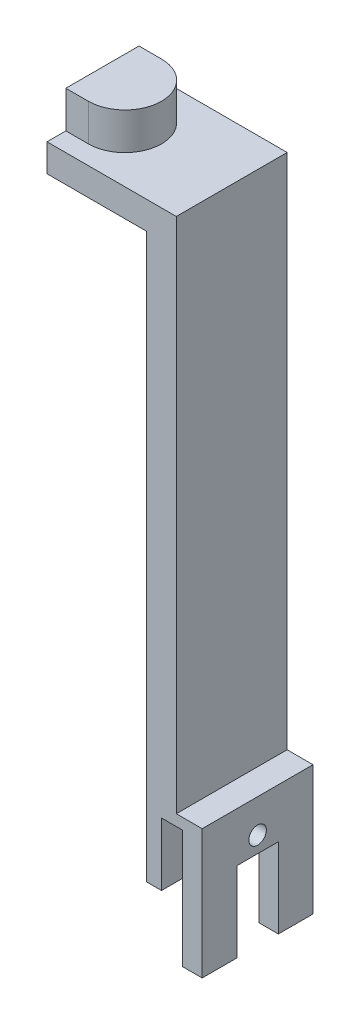
from build123d import *

# Parameters (mm, degrees)
SKETCH_1_W          = 15
SKETCH_1_H          = 30
EXTRUDE_1_DEPTH     = 20
SKETCH_2_W          = 5.7
SKETCH_2_H          = 17
CUT_EXTRUDE_1_DEPTH = 31
SKETCH_3_W          = 8
SKETCH_3_H          = 30
EXTRUDE_2_DEPTH     = 150
SKETCH_4_R          = 2.375
CUT_EXTRUDE_2_DEPTH = 16
SKETCH_5_W          = 30
SKETCH_5_H          = 17.5
EXTRUDE_3_DEPTH     = 27
CUT_EXTRUDE_3_DEPTH = 10
SKETCH_7_W          = 30
SKETCH_7_H          = 15
EXTRUDE_4_DEPTH     = 5.3
CUT_EXTRUDE_4_REACH = 44
SKETCH_8_W          = 11.25
SKETCH_8_H          = 21.625


with BuildPart() as part:
    # 스케치1 → 보스-돌출1 (new body)
    with BuildSketch(Plane(origin=(0, 0, 0), x_dir=(1, 0, 0), z_dir=(0, 1, 0))):
        Rectangle(SKETCH_1_W, SKETCH_1_H)
    extrude(amount=EXTRUDE_1_DEPTH)

    # 스케치2 → 컷-돌출1 (cut, through all)
    with BuildSketch(Plane.XY.offset(15)):
        with Locations((-0.65, 8.5)):
            Rectangle(SKETCH_2_W, SKETCH_2_H)
    extrude(amount=-CUT_EXTRUDE_1_DEPTH, mode=Mode.SUBTRACT)

    # 스케치3 → 보스-돌출2 (add)
    with BuildSketch(Plane(origin=(0, 20, 0), x_dir=(1, 0, 0), z_dir=(0, 1, 0))):
        with Locations((-3.5, 0)):
            Rectangle(SKETCH_3_W, SKETCH_3_H)
    extrude(amount=EXTRUDE_2_DEPTH)

    # 스케치4 → 컷-돌출2 (cut, through all)
    with BuildSketch(Plane(origin=(7.5, 0, 0), x_dir=(0, 0, -1), z_dir=(1, 0, 0))):
        with Locations((0, 11)):
            Circle(SKETCH_4_R)
    extrude(amount=-CUT_EXTRUDE_2_DEPTH, mode=Mode.SUBTRACT)

    # 스케치5 → 보스-돌출3 (add)
    with BuildSketch(Plane.ZY.offset(7.5)):
        with Locations((0, 161.25)):
            Rectangle(SKETCH_5_W, SKETCH_5_H)
    extrude(amount=EXTRUDE_3_DEPTH)

    # 스케치6 → 컷-돌출3 (cut)
    with BuildSketch(Plane(origin=(0, 170, 0), x_dir=(1, 0, 0), z_dir=(0, 1, 0))):
        with BuildLine():
            Line((-34.5, 15), (-34.5, 9.9))
            Line((-34.5, 9.9), (-28.4, 9.9))
            ThreePointArc((-28.4, 9.9), (-18.5, 0), (-28.4, -9.9))
            Line((-28.4, -9.9), (-34.5, -9.9))
            Line((-34.5, -9.9), (-34.5, -15))
            Line((-34.5, -15), (0.5, -15))
            Line((0.5, -15), (0.5, 15))
            Line((0.5, 15), (-34.5, 15))
        make_face()
    extrude(amount=-CUT_EXTRUDE_3_DEPTH, mode=Mode.SUBTRACT)

    # 스케치7 → 보스-돌출4 (add)
    with BuildSketch(Plane(origin=(7.5, 0, 0), x_dir=(0, 0, -1), z_dir=(1, 0, 0))):
        with Locations((0, -7.5)):
            Rectangle(SKETCH_7_W, SKETCH_7_H)
    extrude(amount=-EXTRUDE_4_DEPTH)

    # 스케치8 → 컷-돌출4 (cut, up to next)
    with BuildSketch(Plane(origin=(7.5, 0, 0), x_dir=(0, 0, -1), z_dir=(1, 0, 0)), mode=Mode.PRIVATE) as cut_extrude_4_sk1:
        with Locations((0, -4.1875)):
            Rectangle(SKETCH_8_W, SKETCH_8_H)
    cut_extrude_4_tool1 = extrude(cut_extrude_4_sk1.sketch, amount=-CUT_EXTRUDE_4_REACH, mode=Mode.PRIVATE) & part.part
    add(cut_extrude_4_tool1.solids().sort_by_distance((7.5, -4.1875, 0))[0], mode=Mode.SUBTRACT)


solid = part.part
